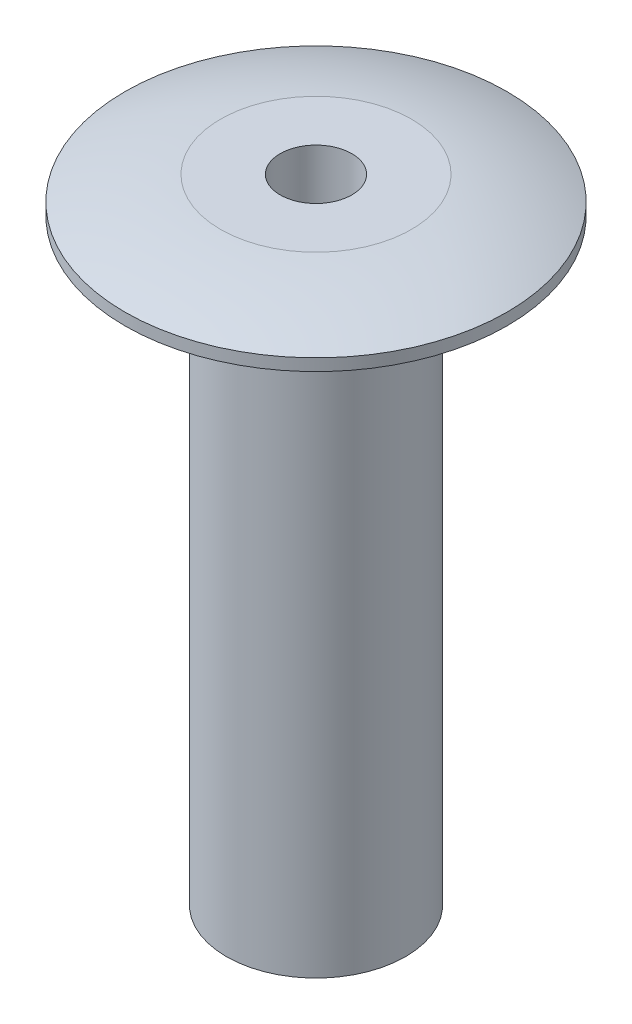
from build123d import *


with BuildPart() as part:
    # Sketch1 → Revolve1 (revolve)
    with BuildSketch(Plane.XY):
        with BuildLine():
            Line((0.6, 0), (1.5, 0))
            Line((1.5, 0), (1.5, 10))
            Line((1.5, 10), (3.2, 10))
            Line((3.2, 10), (3.2, 10.2))
            ThreePointArc((3.2, 10.2), (2.415579075, 10.462316301), (1.6, 10.6))
            Line((1.6, 10.6), (0.6, 10.6))
            Line((0.6, 10.6), (0.6, 0))
        make_face()
    revolve(axis=Axis((0, 0, 0), (0, 1, 0)))


solid = part.part
